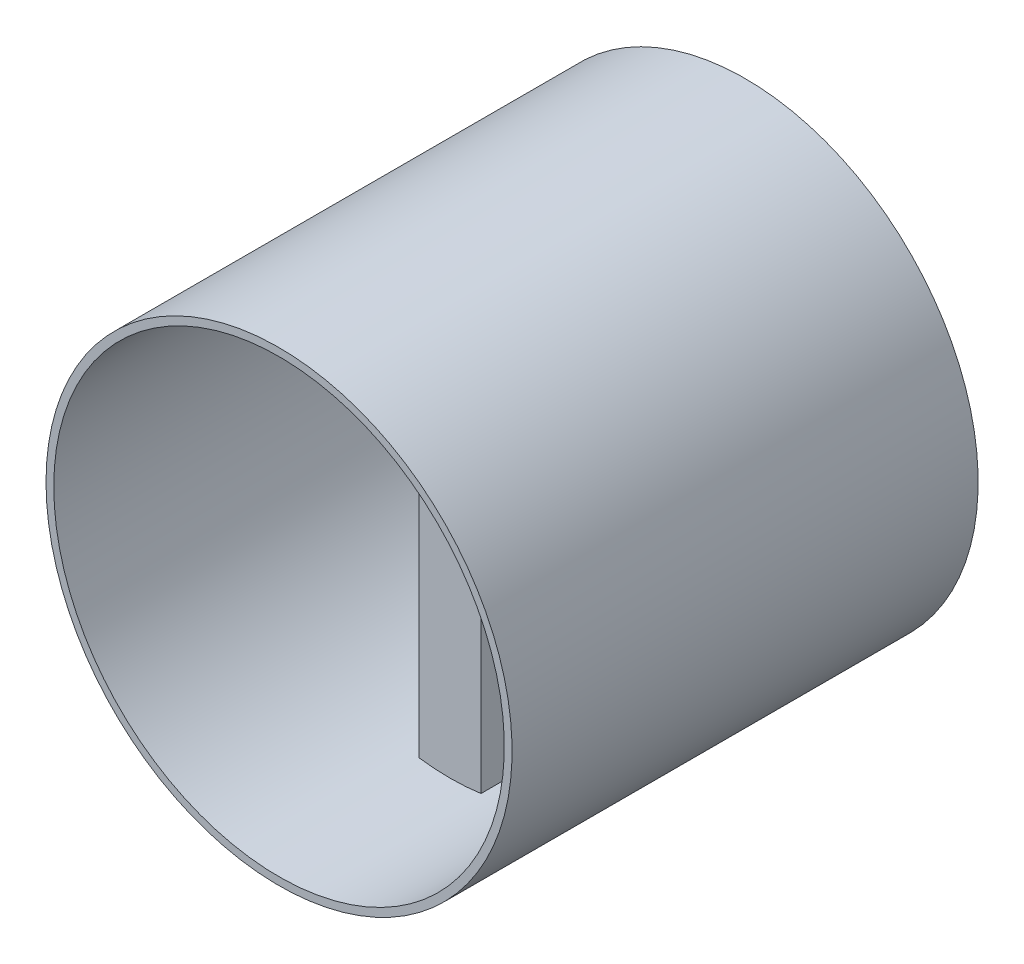
from build123d import *

# Parameters (mm, degrees)
ESQUISSE1_W             = 8
ESQUISSE1_H             = 59
BOSS_EXTRU_1_DEPTH      = 60
ESQUISSE3_R             = 30
ESQUISSE3_R_2           = 29
BOSS_EXTRU_2_DEPTH      = 60
ESQUISSE4_R             = 29
ENL_V_MAT_EXTRU_3_DEPTH = 30
ENL_V_MAT_EXTRU_5_DEPTH = 1.5
ESQUISSE6_R             = 29
ENL_V_MAT_EXTRU_6_DEPTH = 22
ESQUISSE7_R             = 2
ENL_V_MAT_EXTRU_7_DEPTH = 6.5


with BuildPart() as part:
    # Esquisse1 → Boss.-Extru.1 (new body)
    with BuildSketch(Plane.XY):
        with Locations((4, 29.5)):
            Rectangle(ESQUISSE1_W, ESQUISSE1_H)
    extrude(amount=BOSS_EXTRU_1_DEPTH)

    # Esquisse3 → Boss.-Extru.2 (add)
    with BuildSketch(Plane(origin=(0, 0, 0), x_dir=(-1, 0, 0), z_dir=(0, 0, -1))):
        with Locations((-4, 29.5)):
            Circle(ESQUISSE3_R)
        with Locations((-4, 29.5)):
            Circle(ESQUISSE3_R_2, mode=Mode.SUBTRACT)
    extrude(amount=-BOSS_EXTRU_2_DEPTH)

    # Esquisse4 → Enlèv. mat.-Extru.3 (cut)
    with BuildSketch(Plane(origin=(0, 0, 0), x_dir=(-1, 0, 0), z_dir=(0, 0, -1))):
        with Locations((-4, 29.5)):
            Circle(ESQUISSE4_R)
    extrude(amount=-ENL_V_MAT_EXTRU_3_DEPTH, mode=Mode.SUBTRACT)

    # Esquisse5 → Enlèv. mat.-Extru.5 (cut)
    with BuildSketch(Plane(origin=(0, 0, 30), x_dir=(-1, 0, 0), z_dir=(0, 0, -1))):
        with BuildLine():
            Line((-6, 43), (-6.967257844, 29.9420191))
            ThreePointArc((-6.967257844, 29.9420191), (-7, 29.5), (-6.967257844, 29.0579809))
            Line((-6.967257844, 29.0579809), (-6, 16))
            ThreePointArc((-6, 16), (-4, 14), (-2, 16))
            Line((-2, 16), (-1.032742156, 29.0579809))
            ThreePointArc((-1.032742156, 29.0579809), (-1, 29.5), (-1.032742156, 29.9420191))
            Line((-1.032742156, 29.9420191), (-2, 43))
            ThreePointArc((-2, 43), (-4, 45), (-6, 43))
        make_face()
    extrude(amount=-ENL_V_MAT_EXTRU_5_DEPTH, mode=Mode.SUBTRACT)

    # Esquisse6 → Enlèv. mat.-Extru.6 (cut)
    with BuildSketch(Plane.XY.offset(60)):
        with Locations((4, 29.5)):
            Circle(ESQUISSE6_R)
    extrude(amount=-ENL_V_MAT_EXTRU_6_DEPTH, mode=Mode.SUBTRACT)

    # Esquisse7 → Enlèv. mat.-Extru.7 (cut)
    with BuildSketch(Plane(origin=(0, 0, 31.5), x_dir=(-1, 0, 0), z_dir=(0, 0, -1))):
        with Locations((-4, 29.5)):
            Circle(ESQUISSE7_R)
    extrude(amount=-ENL_V_MAT_EXTRU_7_DEPTH, mode=Mode.SUBTRACT)


solid = part.part
